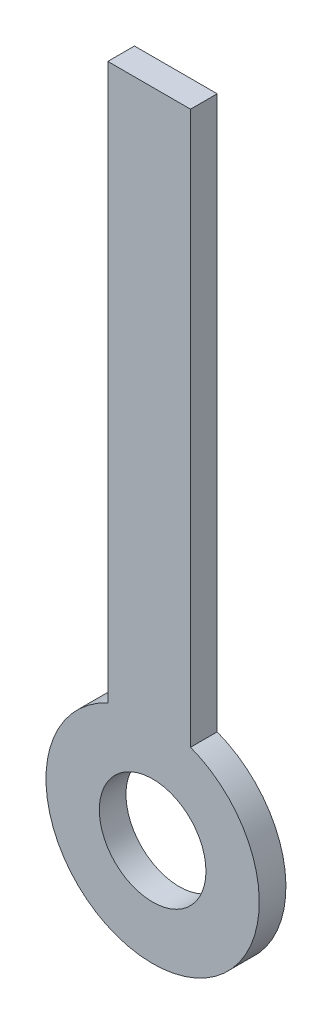
from build123d import *

# Parameters (mm, degrees)
CROQUIS1_R              = 4
SALIENTE_EXTRUIR1_DEPTH = 2
CROQUIS3_W              = 6.205121333
CROQUIS3_H              = 2
SALIENTE_EXTRUIR2_DEPTH = 24.5
CROQUIS4_W              = 6.205121333
CROQUIS4_H              = 2
SALIENTE_EXTRUIR3_DEPTH = 8


with BuildPart() as part:
    # Croquis1 → Saliente-Extruir1 (new body)
    with BuildSketch(Plane.XY):
        with BuildLine():
            Line((-3.36280679, 16.435636067), (-3.36280679, 7.2588932))
            ThreePointArc((-3.36280679, 7.2588932), (0.282374909, -7.995014973), (2.842314543, 7.478051086))
            Line((2.842314543, 7.478051086), (2.842314543, 16.435636067))
            Line((2.842314543, 16.435636067), (-3.36280679, 16.435636067))
        make_face()
        Circle(CROQUIS1_R, mode=Mode.SUBTRACT)
    extrude(amount=SALIENTE_EXTRUIR1_DEPTH)

    # Croquis3 → Saliente-Extruir2 (add)
    with BuildSketch(Plane(origin=(0, 16.435636067, 0), x_dir=(1, 0, 0), z_dir=(0, 1, 0))):
        with Locations((-0.260246123, -1)):
            Rectangle(CROQUIS3_W, CROQUIS3_H)
    extrude(amount=SALIENTE_EXTRUIR2_DEPTH)

    # Croquis4 → Saliente-Extruir3 (add)
    with BuildSketch(Plane(origin=(0, 40.935636067, 0), x_dir=(1, 0, 0), z_dir=(0, 1, 0))):
        with Locations((-0.260246123, -1)):
            Rectangle(CROQUIS4_W, CROQUIS4_H)
    extrude(amount=SALIENTE_EXTRUIR3_DEPTH)


solid = part.part
